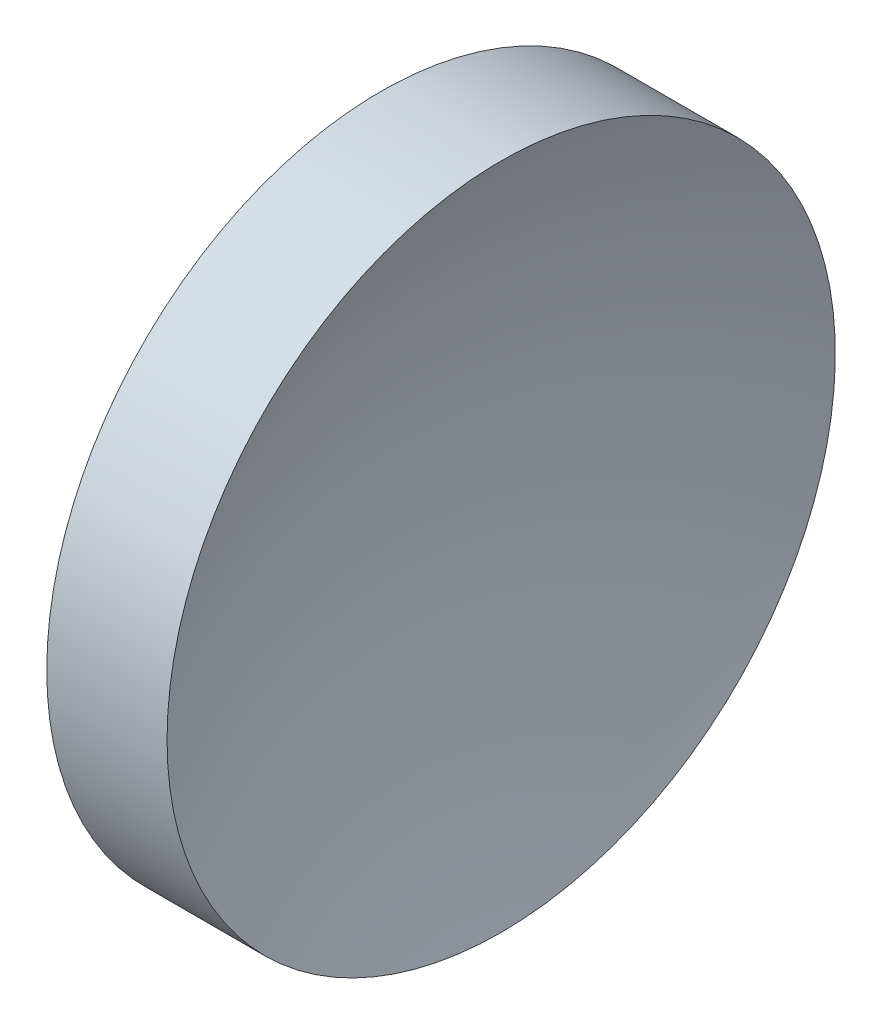
from build123d import *


with BuildPart() as part:
    # 草图1 → 旋转1 (revolve)
    with BuildSketch(Plane.XY, mode=Mode.PRIVATE) as revolve_1_sk:
        with BuildLine():
            Line((57.532337053, 32.610768129), (57.532337053, 45.110768129))
            Line((57.532337053, 45.110768129), (62.032337053, 45.110768129))
            ThreePointArc((62.032337053, 45.110768129), (60.163465093, 38.984542521), (59.532337053, 32.610768129))
            Line((59.532337053, 32.610768129), (57.532337053, 32.610768129))
        make_face()
    revolve(revolve_1_sk.sketch.rotate(Axis((56.10091508, 32.610768129, 0), (1, 0, 0)), 180), axis=Axis((56.10091508, 32.610768129, 0), (1, 0, 0)))  # turned: the seam where the file's is


solid = part.part
